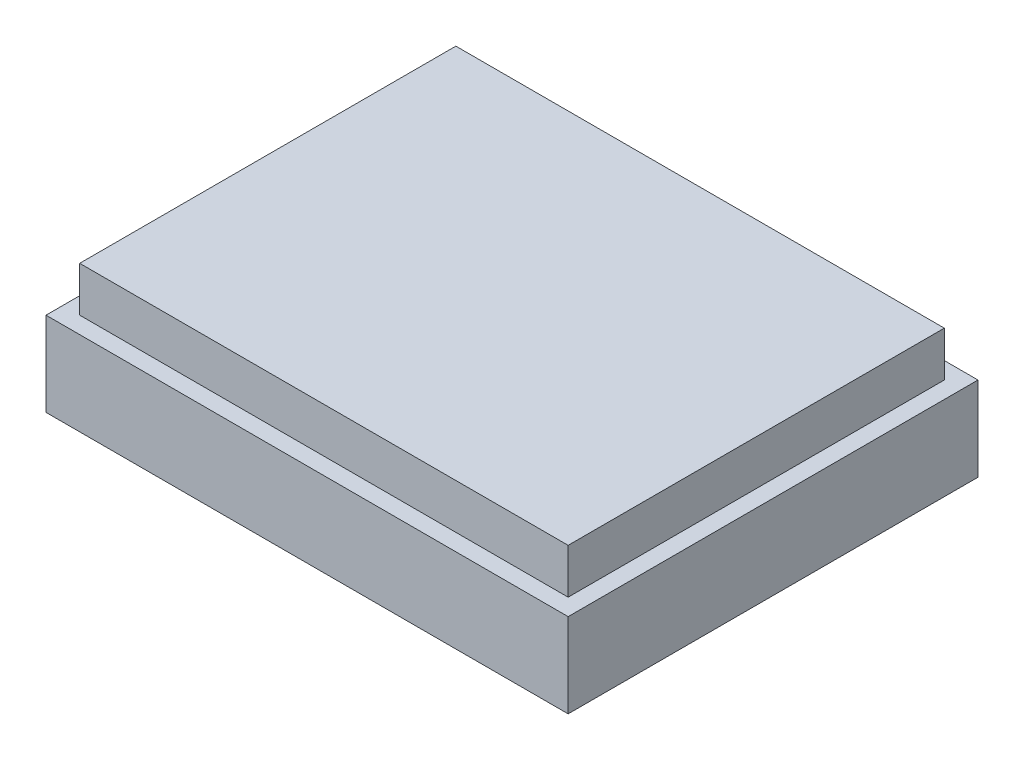
from build123d import *

# Parameters (mm, degrees)
SKETCH1_W           = 118.11
SKETCH1_H           = 92.71
BOSS_EXTRUDE1_DEPTH = 19.05
SKETCH3_W           = 110.49
SKETCH3_H           = 85.09
BOSS_EXTRUDE2_DEPTH = 10.16
CUT_EXTRUDE1_DEPTH  = 2.54


with BuildPart() as part:
    # Sketch1 → Boss-Extrude1 (new body)
    with BuildSketch(Plane(origin=(0, 0, 0), x_dir=(1, 0, 0), z_dir=(0, 1, 0))):
        Rectangle(SKETCH1_W, SKETCH1_H)
    extrude(amount=BOSS_EXTRUDE1_DEPTH)

    # Sketch3 → Boss-Extrude2 (add)
    with BuildSketch(Plane(origin=(0, 19.05, 0), x_dir=(1, 0, 0), z_dir=(0, 1, 0))):
        Rectangle(SKETCH3_W, SKETCH3_H)
    extrude(amount=BOSS_EXTRUDE2_DEPTH)

    # Sketch4 → Cut-Extrude1 (cut)
    with BuildSketch(Plane(origin=(0, 0, -46.355), x_dir=(-1, 0, 0), z_dir=(0, 0, -1))):
        Polygon((38.038942308, 5.250961538), (38.038942308, 4.7625), (35.535576923, 4.7625), (35.535576923, 5.250961538), (36.573557692, 5.250961538), (36.573557692, 9.525), (37.000961538, 9.525), (37.000961538, 5.250961538), align=None)
        with BuildLine():
            add(Edge.make_bspline(
                [(32.452163462, 4.640384615), (32.363968549, 4.642580619), (32.190746463, 4.646893751), (31.936399427, 4.680999474), (31.692851895, 4.737135465), (31.459958405, 4.816406092), (31.238624732, 4.919189844), (31.028151115, 5.043971626), (30.82926101, 5.191977796), (30.642468832, 5.359694946), (30.472692804, 5.544051134), (30.324960148, 5.74197049), (30.19922588, 5.949469449), (30.096496487, 6.167899319), (30.015775283, 6.396284876), (29.960105083, 6.635986661), (29.924536089, 6.885412912), (29.920378385, 7.055538998), (29.918269231, 7.141841947)],
                knots=[0, 0, 0, 0, 0.000264513, 0.000519526, 0.0007683, 0.001013279, 0.001256153, 0.001499123, 0.001746029, 0.00199869, 0.00225122, 0.002496596, 0.002738419, 0.002977836, 0.003219521, 0.003463651, 0.00371501, 0.003973804, 0.003973804, 0.003973804, 0.003973804], degree=3))
            add(Edge.make_bspline(
                [(29.918269231, 7.141841947), (29.920379091, 7.227508674), (29.924537871, 7.396367716), (29.960133984, 7.64421821), (30.016023544, 7.882447136), (30.095497891, 8.110500404), (30.198302954, 8.328489989), (30.324235066, 8.536134129), (30.471635811, 8.734630595), (30.64071575, 8.919884217), (30.825352425, 9.089675905), (31.022048982, 9.239774311), (31.230568068, 9.364814889), (31.44765521, 9.469079997), (31.675470907, 9.548046887), (31.912408435, 9.605591493), (32.159811246, 9.640802022), (32.32834225, 9.644987838), (32.414002404, 9.647115385)],
                knots=[0, 0, 0, 0, 0.000256888, 0.000506357, 0.000749559, 0.000990028, 0.001229445, 0.001471268, 0.001717408, 0.00197, 0.002222531, 0.002469054, 0.002710877, 0.002950702, 0.003190271, 0.003432768, 0.003681292, 0.00393818, 0.00393818, 0.00393818, 0.00393818], degree=3))
            add(Edge.make_bspline(
                [(32.414002404, 9.647115385), (32.500304949, 9.645007395), (32.67043024, 9.640851985), (32.920169287, 9.605222517), (33.160041804, 9.549527977), (33.389309229, 9.469858929), (33.608046797, 9.367283655), (33.816233354, 9.241233876), (34.014119067, 9.092701524), (34.199690222, 8.923754364), (34.369277171, 8.739471741), (34.518438685, 8.54303345), (34.64376176, 8.336307732), (34.746380335, 8.12014675), (34.827547721, 7.895109243), (34.882940478, 7.65977964), (34.918774793, 7.415476622), (34.922904543, 7.249139108), (34.925, 7.164738582)],
                knots=[0, 0, 0, 0, 0.000258795, 0.000510153, 0.000755211, 0.000996582, 0.001236862, 0.001478685, 0.001725396, 0.001977988, 0.002230519, 0.002475705, 0.002716712, 0.002954404, 0.003192493, 0.003432911, 0.0036786, 0.003931676, 0.003931676, 0.003931676, 0.003931676], degree=3))
            add(Edge.make_bspline(
                [(34.925, 7.164738582), (34.924273181, 7.108088155), (34.922828712, 6.995501973), (34.905413058, 6.828319444), (34.880192672, 6.663807521), (34.843858838, 6.502519214), (34.796991274, 6.344428184), (34.739234953, 6.189857736), (34.673046187, 6.037534665), (34.594239318, 5.890357947), (34.508258665, 5.74809658), (34.414505402, 5.612529422), (34.312325837, 5.48607807), (34.203179582, 5.366710653), (34.085555807, 5.256464501), (33.961224747, 5.152935995), (33.829535845, 5.057196823), (33.690280833, 4.971257772), (33.547010068, 4.892321709), (33.398684116, 4.826416592), (33.248432504, 4.768165307), (33.094931758, 4.72187281), (32.938536949, 4.685032964), (32.779052568, 4.66000122), (32.616642881, 4.642546869), (32.507225825, 4.641108468), (32.452163462, 4.640384615)],
                knots=[0, 0, 0, 0, 0.000169884, 0.000337624, 0.000503726, 0.000668982, 0.000833191, 0.000998003, 0.001163743, 0.001331035, 0.001498415, 0.001662233, 0.001825084, 0.00198578, 0.002147078, 0.002308317, 0.002470905, 0.002635033, 0.002798962, 0.002961217, 0.003121564, 0.003282119, 0.003441795, 0.003603186, 0.00376618, 0.003931295, 0.003931295, 0.003931295, 0.003931295], degree=3))
        make_face()
        with BuildLine():
            add(Edge.make_bspline(
                [(32.43117488, 5.128846154), (32.476371188, 5.129394909), (32.566331724, 5.130487172), (32.700058819, 5.144964437), (32.832075073, 5.165430239), (32.96209045, 5.19522984), (33.09022122, 5.233412549), (33.216609606, 5.280562729), (33.341368473, 5.33560737), (33.463356966, 5.399501828), (33.58062688, 5.471120882), (33.693882845, 5.546631145), (33.798799478, 5.630312434), (33.897403278, 5.719061547), (33.989455022, 5.814100432), (34.074967005, 5.91472898), (34.153854983, 6.021402758), (34.225173358, 6.133677308), (34.288640946, 6.250927241), (34.345466193, 6.370910848), (34.392572141, 6.495038293), (34.429887073, 6.622534954), (34.4615589, 6.752838991), (34.481425813, 6.886660344), (34.496041786, 7.023537684), (34.497074042, 7.116042091), (34.497596154, 7.162830529)],
                knots=[0, 0, 0, 0, 0.000135525, 0.000269755, 0.000403074, 0.000536149, 0.000669563, 0.000803891, 0.00094057, 0.001078403, 0.001216658, 0.001352666, 0.001486464, 0.001618858, 0.00175042, 0.001883081, 0.00201474, 0.00214813, 0.002281755, 0.002414488, 0.002546137, 0.002679551, 0.002812842, 0.002948044, 0.003085122, 0.003225416, 0.003225416, 0.003225416, 0.003225416], degree=3))
            add(Edge.make_bspline(
                [(34.497596154, 7.162830529), (34.495857462, 7.231629701), (34.492436917, 7.366978956), (34.462615566, 7.565350069), (34.416314972, 7.756178715), (34.349187856, 7.93832748), (34.263553975, 8.112608614), (34.159098024, 8.27834388), (34.034863408, 8.435484386), (33.893826798, 8.582860379), (33.739606981, 8.717322735), (33.575926722, 8.835515853), (33.404080997, 8.934990477), (33.225060281, 9.018149028), (33.037336126, 9.08079722), (32.842112147, 9.125465352), (32.639384028, 9.154416038), (32.501236565, 9.157227838), (32.43117488, 9.158653846)],
                knots=[0, 0, 0, 0, 0.00020629, 0.000405837, 0.000600433, 0.000794504, 0.000986929, 0.001182003, 0.001381066, 0.001586873, 0.001793112, 0.00199407, 0.002191572, 0.002387937, 0.002585243, 0.002784034, 0.002988171, 0.003198232, 0.003198232, 0.003198232, 0.003198232], degree=3))
            add(Edge.make_bspline(
                [(32.43117488, 9.158653846), (32.38408105, 9.158007344), (32.290679841, 9.156725138), (32.151759741, 9.143792475), (32.015329415, 9.123095066), (31.881641381, 9.093147323), (31.75051885, 9.056164075), (31.622363511, 9.010283032), (31.497195275, 8.955309201), (31.37448402, 8.893944384), (31.256887663, 8.824736379), (31.145741642, 8.748693744), (31.04031504, 8.667852578), (30.941891218, 8.579746182), (30.850223773, 8.485508996), (30.766240083, 8.384454703), (30.687388888, 8.278580043), (30.616570728, 8.166334031), (30.552232488, 8.050011858), (30.497076563, 7.929678963), (30.449943546, 7.806097494), (30.411956344, 7.679145492), (30.382172294, 7.549116864), (30.361653969, 7.415823261), (30.34730025, 7.279535188), (30.346218419, 7.187355131), (30.345673077, 7.140887921)],
                knots=[0, 0, 0, 0, 0.000141247, 0.000280136, 0.000418167, 0.000554966, 0.00069086, 0.000826654, 0.00096295, 0.00110076, 0.001238037, 0.00137193, 0.001504554, 0.00163631, 0.001767872, 0.001898574, 0.002030233, 0.002163622, 0.00229641, 0.002428742, 0.002560391, 0.00269289, 0.002825966, 0.002960226, 0.003097304, 0.003236645, 0.003236645, 0.003236645, 0.003236645], degree=3))
            add(Edge.make_bspline(
                [(30.345673077, 7.140887921), (30.346218877, 7.09473861), (30.347301572, 7.00319295), (30.361646868, 6.867855193), (30.382194865, 6.735521359), (30.411807693, 6.606710971), (30.449975937, 6.48139119), (30.497039417, 6.35967973), (30.552536537, 6.241123122), (30.61622923, 6.126014561), (30.68782406, 6.015558535), (30.766058309, 5.909965307), (30.85227667, 5.811209004), (30.944038338, 5.716885007), (31.043549443, 5.628879914), (31.150827432, 5.547534057), (31.263200911, 5.469181131), (31.383212326, 5.399841241), (31.506620539, 5.33547279), (31.633380954, 5.280602316), (31.761908438, 5.233203114), (31.892374656, 5.195394285), (32.024554236, 5.165401291), (32.158483905, 5.144971853), (32.294113934, 5.130485616), (32.385342918, 5.129394376), (32.43117488, 5.128846154)],
                knots=[0, 0, 0, 0, 0.000138386, 0.000274515, 0.000407833, 0.000539979, 0.000670653, 0.000800519, 0.00093112, 0.001063073, 0.001194856, 0.001325749, 0.001456961, 0.001587841, 0.001720309, 0.001855027, 0.001991572, 0.002130978, 0.002270504, 0.00240893, 0.002545048, 0.002681207, 0.002816144, 0.002951346, 0.003087475, 0.003224908, 0.003224908, 0.003224908, 0.003224908], degree=3))
        make_face(mode=Mode.SUBTRACT)
        Polygon((29.307692308, 4.7625), (28.818276743, 4.7625), (27.56659405, 6.808886719), (26.316819411, 4.7625), (25.827403846, 4.7625), (27.353846154, 7.261095252), (27.353846154, 9.525), (27.78125, 9.525), (27.78125, 7.261095252), align=None)
        Polygon((23.751442308, 5.250961538), (23.751442308, 4.7625), (21.248076923, 4.7625), (21.248076923, 5.250961538), (22.286057692, 5.250961538), (22.286057692, 9.525), (22.713461538, 9.525), (22.713461538, 5.250961538), align=None)
        Polygon((20.759615385, 4.7625), (20.27019982, 4.7625), (19.018517127, 6.808886719), (17.768742488, 4.7625), (17.279326923, 4.7625), (18.805769231, 7.261095252), (18.805769231, 9.525), (19.233173077, 9.525), (19.233173077, 7.261095252), align=None)
        with BuildLine():
            Line((16.485576923, 4.7625), (15.551585036, 4.7625))
            add(Edge.make_bspline(
                [(15.551585036, 4.7625), (15.487344482, 4.762570616), (15.364256726, 4.762705919), (15.187751597, 4.766808127), (15.027446212, 4.772287304), (14.88368623, 4.779882666), (14.756029325, 4.788858741), (14.645053142, 4.801448123), (14.549885389, 4.814593025), (14.492862684, 4.827957153), (14.466856971, 4.834051983)],
                knots=[0, 0, 0, 0, 0.000192716, 0.000369252, 0.00052963, 0.000673891, 0.000801134, 0.000913442, 0.001008969, 0.001089062, 0.001089062, 0.001089062, 0.001089062], degree=3))
            add(Edge.make_bspline(
                [(14.466856971, 4.834051983), (14.433936693, 4.843062837), (14.368871863, 4.860872214), (14.275114203, 4.896537669), (14.185925384, 4.938846218), (14.100932335, 4.986994094), (14.021591086, 5.043255066), (13.945424449, 5.104381942), (13.874029748, 5.172846839), (13.808485022, 5.248559615), (13.747755003, 5.32903995), (13.696919624, 5.41634005), (13.652029984, 5.507431438), (13.617047079, 5.604538139), (13.589549172, 5.706378357), (13.569522416, 5.813217151), (13.556650792, 5.924824043), (13.555429437, 6.001108129), (13.554807692, 6.039941406)],
                knots=[0, 0, 0, 0, 0.000102348, 0.000202284, 0.000300438, 0.000398299, 0.000494901, 0.000591898, 0.000691084, 0.000791152, 0.00089209, 0.000993041, 0.00109374, 0.001196358, 0.001302122, 0.001409897, 0.001522205, 0.001638659, 0.001638659, 0.001638659, 0.001638659], degree=3))
            add(Edge.make_bspline(
                [(13.554807692, 6.039941406), (13.555381131, 6.079099738), (13.556503102, 6.15571566), (13.569969119, 6.267801489), (13.588107701, 6.374914727), (13.615998333, 6.476817872), (13.652527624, 6.57290576), (13.69537931, 6.664646794), (13.747064043, 6.750480204), (13.806452186, 6.830717603), (13.872517034, 6.905434306), (13.944979068, 6.974088865), (14.023545748, 7.036279411), (14.107967385, 7.092145365), (14.199067001, 7.140391231), (14.295462931, 7.183603849), (14.397993047, 7.219895543), (14.468944111, 7.238986448), (14.505018029, 7.248692909)],
                knots=[0, 0, 0, 0, 0.000117407, 0.000229715, 0.000338256, 0.0004431, 0.000546051, 0.000646337, 0.000746469, 0.000846072, 0.000945424, 0.001045301, 0.001145128, 0.001245677, 0.001348544, 0.001454032, 0.001562359, 0.001674403, 0.001674403, 0.001674403, 0.001674403], degree=3))
            add(Edge.make_bspline(
                [(14.505018029, 7.248692909), (14.534855205, 7.255033165), (14.600245112, 7.268928205), (14.707928992, 7.284545841), (14.833368646, 7.297354009), (14.976137272, 7.309306694), (15.136567804, 7.315640123), (15.314292291, 7.323076601), (15.509912211, 7.326585469), (15.646351007, 7.326807273), (15.717585637, 7.326923077)],
                knots=[0, 0, 0, 0, 9.1492e-05, 0.00020051, 0.000326199, 0.000469761, 0.000630219, 0.000807793, 0.001003406, 0.00121711, 0.00121711, 0.00121711, 0.00121711], degree=3))
            Line((15.717585637, 7.326923077), (16.058173077, 7.326923077))
            Line((16.058173077, 7.326923077), (16.058173077, 9.525))
            Line((16.058173077, 9.525), (16.485576923, 9.525))
            Line((16.485576923, 9.525), (16.485576923, 4.7625))
        make_face()
        with BuildLine():
            Line((16.058173077, 5.250961538), (16.058173077, 6.838461538))
            Line((16.058173077, 6.838461538), (15.224353966, 6.848955829))
            add(Edge.make_bspline(
                [(15.224353966, 6.848955829), (15.183640811, 6.848982674), (15.105044903, 6.849034498), (14.991204145, 6.84351876), (14.885840458, 6.837518259), (14.788798277, 6.827814024), (14.700520527, 6.815977882), (14.620793478, 6.800152902), (14.548980869, 6.784012443), (14.466260696, 6.756005884), (14.373605426, 6.713754434), (14.273041646, 6.650646627), (14.187118143, 6.571146659), (14.11339165, 6.480794119), (14.055115893, 6.380174846), (14.012880926, 6.272816989), (13.987101579, 6.159128202), (13.983861333, 6.081416796), (13.982211538, 6.041849459)],
                knots=[0, 0, 0, 0, 0.000122119, 0.000235748, 0.000341856, 0.000438684, 0.000528271, 0.000608913, 0.000682497, 0.000748868, 0.000870539, 0.000987247, 0.001103403, 0.001220068, 0.001335918, 0.001450719, 0.001565063, 0.001683673, 0.001683673, 0.001683673, 0.001683673], degree=3))
            add(Edge.make_bspline(
                [(13.982211538, 6.041849459), (13.983934937, 6.003563995), (13.987360841, 5.92745723), (14.012667979, 5.815863109), (14.055563175, 5.709725743), (14.11343916, 5.609903972), (14.185398907, 5.519791576), (14.26961357, 5.442063371), (14.364772898, 5.379151489), (14.452601003, 5.337271649), (14.531200241, 5.312712379), (14.599142133, 5.294981829), (14.676245787, 5.282753446), (14.761781515, 5.271053183), (14.855639803, 5.261608525), (14.958417473, 5.255049852), (15.06977218, 5.251251668), (15.147074773, 5.25106059), (15.187146935, 5.250961538)],
                knots=[0, 0, 0, 0, 0.000114805, 0.000228218, 0.000341245, 0.000457095, 0.000573161, 0.000685918, 0.000799431, 0.00091424, 0.000976391, 0.00104627, 0.001124692, 0.001210368, 0.001305297, 0.001407596, 0.001519283, 0.001639494, 0.001639494, 0.001639494, 0.001639494], degree=3))
            Line((15.187146935, 5.250961538), (16.058173077, 5.250961538))
        make_face(mode=Mode.SUBTRACT)
        Polygon((12.577884615, 4.7625), (9.891346154, 4.7625), (9.891346154, 5.250961538), (12.150480769, 5.250961538), (12.150480769, 6.716346154), (9.891346154, 6.716346154), (9.891346154, 7.204807692), (12.150480769, 7.204807692), (12.150480769, 9.036538462), (9.891346154, 9.036538462), (9.891346154, 9.525), (12.577884615, 9.525), align=None)
        with BuildLine():
            Line((2.808653846, 5.636388221), (3.182632212, 5.922596154))
            add(Edge.make_bspline(
                [(3.182632212, 5.922596154), (3.209310497, 5.890802166), (3.262307388, 5.827642841), (3.347564641, 5.738945923), (3.436436555, 5.655876667), (3.528799476, 5.577901341), (3.626790896, 5.508153935), (3.726677066, 5.441202463), (3.832087294, 5.382584145), (3.977109315, 5.310974536), (4.167562585, 5.237879221), (4.406483388, 5.17501094), (4.656236805, 5.135367647), (4.826588455, 5.131044885), (4.913236178, 5.128846154)],
                knots=[0, 0, 0, 0, 0.000124485, 0.000247292, 0.000368787, 0.000489349, 0.000609572, 0.000729438, 0.000849902, 0.000971075, 0.001214507, 0.001460263, 0.001711228, 0.001971019, 0.001971019, 0.001971019, 0.001971019], degree=3))
            add(Edge.make_bspline(
                [(4.913236178, 5.128846154), (4.960973944, 5.129398312), (5.056006425, 5.130497503), (5.197050948, 5.144896887), (5.335728869, 5.165368475), (5.471524496, 5.195005349), (5.604168201, 5.233589868), (5.734669948, 5.278839216), (5.86149281, 5.335147415), (5.986162932, 5.397332384), (6.105600152, 5.467589672), (6.21863082, 5.544199074), (6.324745154, 5.626403782), (6.424213022, 5.714009537), (6.516032133, 5.808039072), (6.601177922, 5.90743591), (6.679541709, 6.012648936), (6.751042642, 6.123175433), (6.814995718, 6.238469437), (6.870453425, 6.358035708), (6.917331466, 6.481417471), (6.955361892, 6.608350304), (6.985126057, 6.738384896), (7.005729198, 6.871986841), (7.019995921, 7.008922611), (7.021085427, 7.101735713), (7.021634615, 7.148520132)],
                knots=[0, 0, 0, 0, 0.000143155, 0.000284981, 0.000424898, 0.00056356, 0.000701552, 0.000839143, 0.000977569, 0.001117512, 0.001256918, 0.001392926, 0.001526888, 0.001659357, 0.001790236, 0.001920826, 0.002051719, 0.002183502, 0.002315455, 0.00244692, 0.002578569, 0.002711069, 0.002844144, 0.002978405, 0.003116432, 0.003256726, 0.003256726, 0.003256726, 0.003256726], degree=3))
            add(Edge.make_bspline(
                [(7.021634615, 7.148520132), (7.019913614, 7.218910109), (7.016534657, 7.357111492), (6.986590325, 7.559568062), (6.940721476, 7.75370778), (6.873102084, 7.938216143), (6.78805997, 8.114631251), (6.681950862, 8.280813711), (6.558592798, 8.439198144), (6.416720285, 8.585948572), (6.26104254, 8.71999571), (6.094018794, 8.838038968), (5.916058456, 8.936438728), (5.729128191, 9.018321034), (5.531789065, 9.081263215), (5.324396072, 9.125573685), (5.107400248, 9.154478223), (4.959124029, 9.157245492), (4.883661358, 9.158653846)],
                knots=[0, 0, 0, 0, 0.000211056, 0.00041438, 0.000612682, 0.000808546, 0.001002685, 0.001199075, 0.001398888, 0.001604006, 0.001810343, 0.002014411, 0.002216417, 0.002419358, 0.002625728, 0.002836619, 0.003054944, 0.003281211, 0.003281211, 0.003281211, 0.003281211], degree=3))
            add(Edge.make_bspline(
                [(4.883661358, 9.158653846), (4.800518056, 9.156355899), (4.636872149, 9.151832991), (4.396885656, 9.113516298), (4.167148418, 9.051388917), (3.947648077, 8.964442101), (3.739003433, 8.851413977), (3.540887977, 8.714392937), (3.353134483, 8.552075598), (3.240234274, 8.428137485), (3.182632212, 8.364903846)],
                knots=[0, 0, 0, 0, 0.00024931, 0.000490701, 0.000726995, 0.000962085, 0.001197283, 0.001437307, 0.001683487, 0.001939923, 0.001939923, 0.001939923, 0.001939923], degree=3))
            Line((3.182632212, 8.364903846), (2.808653846, 8.6482497))
            add(Edge.make_bspline(
                [(2.808653846, 8.6482497), (2.83875129, 8.687081101), (2.898802011, 8.764557904), (2.996020896, 8.873803715), (3.098508048, 8.97647235), (3.206540136, 9.072029118), (3.320258189, 9.160951645), (3.439612505, 9.242826459), (3.564007786, 9.318561797), (3.693599794, 9.387206984), (3.828395624, 9.448289734), (3.967240103, 9.501675918), (4.11038757, 9.546503914), (4.25670919, 9.584168711), (4.407708415, 9.61106857), (4.561657551, 9.632476742), (4.71998996, 9.645180484), (4.826715306, 9.646464632), (4.880799279, 9.647115385)],
                knots=[0, 0, 0, 0, 0.000147356, 0.000294007, 0.000438371, 0.000582327, 0.000726414, 0.000871165, 0.001016293, 0.001163102, 0.001310828, 0.001460011, 0.001609065, 0.001760623, 0.001912939, 0.00206891, 0.002226812, 0.002389041, 0.002389041, 0.002389041, 0.002389041], degree=3))
            add(Edge.make_bspline(
                [(4.880799279, 9.647115385), (4.932021554, 9.646758888), (5.033307261, 9.646053959), (5.182848063, 9.634634617), (5.328430314, 9.619054796), (5.469637929, 9.595595904), (5.607241488, 9.567913069), (5.739993569, 9.530804681), (5.869200481, 9.489235994), (5.994343116, 9.440379565), (6.115527921, 9.385248617), (6.232364036, 9.322939388), (6.344797725, 9.253975851), (6.453934387, 9.179878141), (6.558161813, 9.098266169), (6.658383217, 9.010273356), (6.755160586, 8.916196277), (6.815035669, 8.848358066), (6.845139724, 8.8142503)],
                knots=[0, 0, 0, 0, 0.000153625, 0.000303774, 0.00044969, 0.000592731, 0.00073306, 0.000870536, 0.001005998, 0.001140112, 0.001273311, 0.001405191, 0.001537068, 0.001668848, 0.001800718, 0.001933903, 0.002068829, 0.002205265, 0.002205265, 0.002205265, 0.002205265], degree=3))
            add(Edge.make_bspline(
                [(6.845139724, 8.8142503), (6.893354365, 8.75500196), (6.989201558, 8.637220578), (7.111883168, 8.446349435), (7.216547832, 8.247241246), (7.302117735, 8.03874274), (7.367845402, 7.820772866), (7.414056226, 7.593682273), (7.443875999, 7.357924926), (7.447298688, 7.197584984), (7.449038462, 7.116083233)],
                knots=[0, 0, 0, 0, 0.000229016, 0.000455267, 0.000679301, 0.00090306, 0.001130321, 0.001361207, 0.001597636, 0.001842053, 0.001842053, 0.001842053, 0.001842053], degree=3))
            add(Edge.make_bspline(
                [(7.449038462, 7.116083233), (7.446912822, 7.030422432), (7.44273076, 6.861890154), (7.407493002, 6.614496585), (7.350119124, 6.377817116), (7.271114911, 6.150941061), (7.166887232, 5.935166518), (7.040711197, 5.72958218), (6.891354371, 5.534355912), (6.720692534, 5.351983701), (6.533492834, 5.185247096), (6.333036598, 5.038552493), (6.119700483, 4.916472893), (5.895838874, 4.814424462), (5.659774379, 4.73598684), (5.412010951, 4.681077676), (5.153014067, 4.646900459), (4.97630841, 4.642579908), (4.886523438, 4.640384615)],
                knots=[0, 0, 0, 0, 0.000256888, 0.000505412, 0.000747909, 0.000986578, 0.001224681, 0.00146537, 0.001709038, 0.001960816, 0.002213552, 0.002460099, 0.002704576, 0.002949655, 0.00319704, 0.003449322, 0.00371001, 0.003979289, 0.003979289, 0.003979289, 0.003979289], degree=3))
            add(Edge.make_bspline(
                [(4.886523438, 4.640384615), (4.831803103, 4.641040748), (4.723489713, 4.642339497), (4.563260948, 4.65500133), (4.407269352, 4.676115209), (4.255080978, 4.704889919), (4.106444801, 4.740680127), (3.962028803, 4.785494196), (3.822246775, 4.839677367), (3.686156166, 4.899981895), (3.555501884, 4.969046861), (3.430348921, 5.044117372), (3.311713494, 5.126639034), (3.198824416, 5.215408296), (3.092203608, 5.311108048), (2.990250911, 5.4121297), (2.895993524, 5.521153051), (2.837820366, 5.597906183), (2.808653846, 5.636388221)],
                knots=[0, 0, 0, 0, 0.000164137, 0.000324892, 0.000481809, 0.000636175, 0.000789355, 0.00094023, 0.001089413, 0.001238879, 0.001386531, 0.001532475, 0.001676442, 0.001819777, 0.001963021, 0.002106036, 0.002250082, 0.002394921, 0.002394921, 0.002394921, 0.002394921], degree=3))
        make_face()
        with BuildLine():
            add(Edge.make_bspline(
                [(-0.396875, 4.640384615), (-0.485069913, 4.642580619), (-0.658291998, 4.646893751), (-0.912639034, 4.680999474), (-1.156186566, 4.737135465), (-1.389080057, 4.816406092), (-1.61041373, 4.919189844), (-1.820887346, 5.043971626), (-2.019777451, 5.191977796), (-2.20656963, 5.359694946), (-2.376345657, 5.544051134), (-2.524078314, 5.74197049), (-2.649812582, 5.949469449), (-2.752541974, 6.167899319), (-2.833263179, 6.396284876), (-2.888933379, 6.635986661), (-2.924502372, 6.885412912), (-2.928660077, 7.055538998), (-2.930769231, 7.141841947)],
                knots=[0, 0, 0, 0, 0.000264513, 0.000519526, 0.0007683, 0.001013279, 0.001256153, 0.001499123, 0.001746029, 0.00199869, 0.00225122, 0.002496596, 0.002738419, 0.002977836, 0.003219521, 0.003463651, 0.00371501, 0.003973804, 0.003973804, 0.003973804, 0.003973804], degree=3))
            add(Edge.make_bspline(
                [(-2.930769231, 7.141841947), (-2.92865937, 7.227508674), (-2.924500591, 7.396367716), (-2.888904478, 7.64421821), (-2.833014918, 7.882447136), (-2.753540571, 8.110500404), (-2.650735508, 8.328489989), (-2.524803396, 8.536134129), (-2.377402651, 8.734630595), (-2.208322711, 8.919884217), (-2.023686036, 9.089675905), (-1.826989479, 9.239774311), (-1.618470393, 9.364814889), (-1.401383251, 9.469079997), (-1.173567554, 9.548046887), (-0.936630027, 9.605591493), (-0.689227215, 9.640802022), (-0.520696211, 9.644987838), (-0.435036058, 9.647115385)],
                knots=[0, 0, 0, 0, 0.000256888, 0.000506357, 0.000749559, 0.000990028, 0.001229445, 0.001471268, 0.001717408, 0.00197, 0.002222531, 0.002469054, 0.002710877, 0.002950702, 0.003190271, 0.003432768, 0.003681292, 0.00393818, 0.00393818, 0.00393818, 0.00393818], degree=3))
            add(Edge.make_bspline(
                [(-0.435036058, 9.647115385), (-0.348733512, 9.645007395), (-0.178608221, 9.640851985), (0.071130825, 9.605222517), (0.311003343, 9.549527977), (0.540270768, 9.469858929), (0.759008336, 9.367283655), (0.967194892, 9.241233876), (1.165080606, 9.092701524), (1.35065176, 8.923754364), (1.520238709, 8.739471741), (1.669400223, 8.54303345), (1.794723298, 8.336307732), (1.897341874, 8.12014675), (1.97850926, 7.895109243), (2.033902017, 7.65977964), (2.069736332, 7.415476622), (2.073866082, 7.249139108), (2.075961538, 7.164738582)],
                knots=[0, 0, 0, 0, 0.000258795, 0.000510153, 0.000755211, 0.000996582, 0.001236862, 0.001478685, 0.001725396, 0.001977988, 0.002230519, 0.002475705, 0.002716712, 0.002954404, 0.003192493, 0.003432911, 0.0036786, 0.003931676, 0.003931676, 0.003931676, 0.003931676], degree=3))
            add(Edge.make_bspline(
                [(2.075961538, 7.164738582), (2.075234719, 7.108088155), (2.07379025, 6.995501973), (2.056374597, 6.828319444), (2.03115421, 6.663807521), (1.994820376, 6.502519214), (1.947952813, 6.344428184), (1.890196492, 6.189857736), (1.824007725, 6.037534665), (1.745200856, 5.890357947), (1.659220203, 5.74809658), (1.56546694, 5.612529422), (1.463287375, 5.48607807), (1.35414112, 5.366710653), (1.236517345, 5.256464501), (1.112186285, 5.152935995), (0.980497384, 5.057196823), (0.841242371, 4.971257772), (0.697971607, 4.892321709), (0.549645655, 4.826416592), (0.399394043, 4.768165307), (0.245893296, 4.72187281), (0.089498488, 4.685032964), (-0.069985894, 4.66000122), (-0.232395581, 4.642546869), (-0.341812637, 4.641108468), (-0.396875, 4.640384615)],
                knots=[0, 0, 0, 0, 0.000169884, 0.000337624, 0.000503726, 0.000668982, 0.000833191, 0.000998003, 0.001163743, 0.001331035, 0.001498415, 0.001662233, 0.001825084, 0.00198578, 0.002147078, 0.002308317, 0.002470905, 0.002635033, 0.002798962, 0.002961217, 0.003121564, 0.003282119, 0.003441795, 0.003603186, 0.00376618, 0.003931295, 0.003931295, 0.003931295, 0.003931295], degree=3))
        make_face()
        with BuildLine():
            add(Edge.make_bspline(
                [(-0.417863582, 5.128846154), (-0.372667274, 5.129394909), (-0.282706738, 5.130487172), (-0.148979643, 5.144964437), (-0.016963388, 5.165430239), (0.113051988, 5.19522984), (0.241182758, 5.233412549), (0.367571144, 5.280562729), (0.492330012, 5.33560737), (0.614318505, 5.399501828), (0.731588419, 5.471120882), (0.844844384, 5.546631145), (0.949761017, 5.630312434), (1.048364817, 5.719061547), (1.14041656, 5.814100432), (1.225928544, 5.91472898), (1.304816521, 6.021402758), (1.376134896, 6.133677308), (1.439602485, 6.250927241), (1.496427731, 6.370910848), (1.543533679, 6.495038293), (1.580848611, 6.622534954), (1.612520438, 6.752838991), (1.632387352, 6.886660344), (1.647003325, 7.023537684), (1.648035581, 7.116042091), (1.648557692, 7.162830529)],
                knots=[0, 0, 0, 0, 0.000135525, 0.000269755, 0.000403074, 0.000536149, 0.000669563, 0.000803891, 0.00094057, 0.001078403, 0.001216658, 0.001352666, 0.001486464, 0.001618858, 0.00175042, 0.001883081, 0.00201474, 0.00214813, 0.002281755, 0.002414488, 0.002546137, 0.002679551, 0.002812842, 0.002948044, 0.003085122, 0.003225416, 0.003225416, 0.003225416, 0.003225416], degree=3))
            add(Edge.make_bspline(
                [(1.648557692, 7.162830529), (1.646819, 7.231629701), (1.643398456, 7.366978956), (1.613577104, 7.565350069), (1.56727651, 7.756178715), (1.500149395, 7.93832748), (1.414515513, 8.112608614), (1.310059563, 8.27834388), (1.185824947, 8.435484386), (1.044788336, 8.582860379), (0.890568519, 8.717322735), (0.72688826, 8.835515853), (0.555042535, 8.934990477), (0.376021819, 9.018149028), (0.188297664, 9.08079722), (-0.006926315, 9.125465352), (-0.209654433, 9.154416038), (-0.347801896, 9.157227838), (-0.417863582, 9.158653846)],
                knots=[0, 0, 0, 0, 0.00020629, 0.000405837, 0.000600433, 0.000794504, 0.000986929, 0.001182003, 0.001381066, 0.001586873, 0.001793112, 0.00199407, 0.002191572, 0.002387937, 0.002585243, 0.002784034, 0.002988171, 0.003198232, 0.003198232, 0.003198232, 0.003198232], degree=3))
            add(Edge.make_bspline(
                [(-0.417863582, 9.158653846), (-0.464957412, 9.158007344), (-0.558358621, 9.156725138), (-0.697278721, 9.143792475), (-0.833709046, 9.123095066), (-0.967397081, 9.093147323), (-1.098519611, 9.056164075), (-1.22667495, 9.010283032), (-1.351843186, 8.955309201), (-1.474554442, 8.893944384), (-1.592150799, 8.824736379), (-1.70329682, 8.748693744), (-1.808723421, 8.667852578), (-1.907147244, 8.579746182), (-1.998814688, 8.485508996), (-2.082798378, 8.384454703), (-2.161649574, 8.278580043), (-2.232467733, 8.166334031), (-2.296805974, 8.050011858), (-2.351961898, 7.929678963), (-2.399094915, 7.806097494), (-2.437082118, 7.679145492), (-2.466866168, 7.549116864), (-2.487384493, 7.415823261), (-2.501738211, 7.279535188), (-2.502820042, 7.187355131), (-2.503365385, 7.140887921)],
                knots=[0, 0, 0, 0, 0.000141247, 0.000280136, 0.000418167, 0.000554966, 0.00069086, 0.000826654, 0.00096295, 0.00110076, 0.001238037, 0.00137193, 0.001504554, 0.00163631, 0.001767872, 0.001898574, 0.002030233, 0.002163622, 0.00229641, 0.002428742, 0.002560391, 0.00269289, 0.002825966, 0.002960226, 0.003097304, 0.003236645, 0.003236645, 0.003236645, 0.003236645], degree=3))
            add(Edge.make_bspline(
                [(-2.503365385, 7.140887921), (-2.502819584, 7.09473861), (-2.501736889, 7.00319295), (-2.487391593, 6.867855193), (-2.466843596, 6.735521359), (-2.437230768, 6.606710971), (-2.399062525, 6.48139119), (-2.351999045, 6.35967973), (-2.296501925, 6.241123122), (-2.232809232, 6.126014561), (-2.161214402, 6.015558535), (-2.082980153, 5.909965307), (-1.996761792, 5.811209004), (-1.905000123, 5.716885007), (-1.805489019, 5.628879914), (-1.698211029, 5.547534057), (-1.58583755, 5.469181131), (-1.465826135, 5.399841241), (-1.342417922, 5.33547279), (-1.215657507, 5.280602316), (-1.087130024, 5.233203114), (-0.956663806, 5.195394285), (-0.824484226, 5.165401291), (-0.690554556, 5.144971853), (-0.554924527, 5.130485616), (-0.463695544, 5.129394376), (-0.417863582, 5.128846154)],
                knots=[0, 0, 0, 0, 0.000138386, 0.000274515, 0.000407833, 0.000539979, 0.000670653, 0.000800519, 0.00093112, 0.001063073, 0.001194856, 0.001325749, 0.001456961, 0.001587841, 0.001720309, 0.001855027, 0.001991572, 0.002130978, 0.002270504, 0.00240893, 0.002545048, 0.002681207, 0.002816144, 0.002951346, 0.003087475, 0.003224908, 0.003224908, 0.003224908, 0.003224908], degree=3))
        make_face(mode=Mode.SUBTRACT)
        Polygon((-3.907692308, 9.525), (-3.907692308, 4.7625), (-3.997370793, 4.7625), (-7.14375, 8.510869892), (-7.14375, 4.7625), (-7.571153846, 4.7625), (-7.571153846, 9.525), (-7.473843149, 9.525), (-4.335096154, 5.785216346), (-4.335096154, 9.525), align=None)
        Polygon((-8.425961538, 4.7625), (-8.883894231, 4.7625), (-10.471394231, 8.515640024), (-12.058894231, 4.7625), (-12.516826923, 4.7625), (-10.501923077, 9.525), (-10.440865385, 9.525), align=None)
        Polygon((-13.432692308, 4.7625), (-16.119230769, 4.7625), (-16.119230769, 5.250961538), (-13.860096154, 5.250961538), (-13.860096154, 6.716346154), (-16.119230769, 6.716346154), (-16.119230769, 7.204807692), (-13.860096154, 7.204807692), (-13.860096154, 9.036538462), (-16.119230769, 9.036538462), (-16.119230769, 9.525), (-13.432692308, 9.525), align=None)
        with BuildLine():
            Line((-16.974038462, 4.7625), (-17.927110877, 4.7625))
            add(Edge.make_bspline(
                [(-17.927110877, 4.7625), (-17.990712199, 4.762711708), (-18.112833781, 4.763118211), (-18.287785267, 4.765384838), (-18.446753567, 4.771881372), (-18.589655562, 4.777471981), (-18.716488632, 4.787666372), (-18.827641695, 4.797409967), (-18.922602812, 4.810164841), (-18.980087346, 4.822010435), (-19.006114784, 4.827373798)],
                knots=[0, 0, 0, 0, 0.000190808, 0.000366372, 0.000524844, 0.000668103, 0.000795347, 0.000906511, 0.001002844, 0.001082549, 0.001082549, 0.001082549, 0.001082549], degree=3))
            add(Edge.make_bspline(
                [(-19.006114784, 4.827373798), (-19.04095867, 4.835981765), (-19.109903127, 4.853014067), (-19.209158813, 4.889031854), (-19.303779347, 4.930645392), (-19.393418228, 4.979895354), (-19.478051965, 5.035950093), (-19.557672033, 5.09903495), (-19.631210882, 5.169690434), (-19.701284912, 5.244989716), (-19.762472925, 5.328211235), (-19.817558369, 5.415131719), (-19.863800712, 5.507424605), (-19.900188275, 5.604624387), (-19.930693035, 5.705777586), (-19.951195081, 5.811883731), (-19.963964114, 5.922597608), (-19.965225695, 5.997928502), (-19.965865385, 6.0361253)],
                knots=[0, 0, 0, 0, 0.000107606, 0.000212917, 0.000316274, 0.000417464, 0.000519335, 0.000620502, 0.000721728, 0.00082505, 0.000928657, 0.001031098, 0.001133495, 0.001237676, 0.001342124, 0.001450081, 0.00156144, 0.001675987, 0.001675987, 0.001675987, 0.001675987], degree=3))
            add(Edge.make_bspline(
                [(-19.965865385, 6.0361253), (-19.96386655, 6.099582427), (-19.959966305, 6.223403715), (-19.92360035, 6.403099823), (-19.864035664, 6.570729013), (-19.781943141, 6.726058004), (-19.677449912, 6.866140846), (-19.551872813, 6.988764025), (-19.405853156, 7.092324886), (-19.26928023, 7.163376765), (-19.148581629, 7.209094589), (-19.048923364, 7.241423299), (-18.940130496, 7.265980078), (-18.823763823, 7.288298759), (-18.698924519, 7.305329706), (-18.565863979, 7.317424915), (-18.42424941, 7.325202226), (-18.327176377, 7.326338525), (-18.277238582, 7.326923077)],
                knots=[0, 0, 0, 0, 0.000190196, 0.000371122, 0.000547346, 0.000722326, 0.00089615, 0.001069534, 0.001246646, 0.001431405, 0.001529558, 0.001633652, 0.00174542, 0.001863862, 0.001989068, 0.002123207, 0.002264609, 0.002414418, 0.002414418, 0.002414418, 0.002414418], degree=3))
            Line((-18.277238582, 7.326923077), (-20.026923077, 9.525))
            Line((-20.026923077, 9.525), (-19.498392428, 9.525))
            Line((-19.498392428, 9.525), (-17.748707933, 7.326923077))
            Line((-17.748707933, 7.326923077), (-17.401442308, 7.326923077))
            Line((-17.401442308, 7.326923077), (-17.401442308, 9.525))
            Line((-17.401442308, 9.525), (-16.974038462, 9.525))
            Line((-16.974038462, 9.525), (-16.974038462, 4.7625))
        make_face()
        with BuildLine():
            Line((-17.401442308, 5.250961538), (-17.401442308, 6.838461538))
            Line((-17.401442308, 6.838461538), (-18.273422476, 6.845139724))
            add(Edge.make_bspline(
                [(-18.273422476, 6.845139724), (-18.314135105, 6.845157745), (-18.393047777, 6.845192676), (-18.507212541, 6.839758148), (-18.613511929, 6.833576466), (-18.711538021, 6.824118803), (-18.801339014, 6.811937371), (-18.882855595, 6.796676275), (-18.956267904, 6.778971659), (-19.041615498, 6.751289126), (-19.138015747, 6.709322249), (-19.240620844, 6.644248957), (-19.330346062, 6.565552402), (-19.404942675, 6.474426014), (-19.464858759, 6.37380365), (-19.506475816, 6.265962541), (-19.533901215, 6.152601831), (-19.536923905, 6.074766094), (-19.538461538, 6.035171274)],
                knots=[0, 0, 0, 0, 0.000122119, 0.000236702, 0.000342809, 0.000441536, 0.000532068, 0.000614584, 0.000690247, 0.000758432, 0.000883584, 0.001004535, 0.001121476, 0.001240087, 0.001356419, 0.00147122, 0.001585775, 0.001704385, 0.001704385, 0.001704385, 0.001704385], degree=3))
            add(Edge.make_bspline(
                [(-19.538461538, 6.035171274), (-19.536846049, 5.996864339), (-19.533644737, 5.920953972), (-19.506912488, 5.810073265), (-19.463262959, 5.704640266), (-19.403517957, 5.606105801), (-19.329158894, 5.517324857), (-19.242547334, 5.441594585), (-19.145721438, 5.378680033), (-19.055957531, 5.337168859), (-18.975138403, 5.312743619), (-18.905290842, 5.295013364), (-18.825680975, 5.282595897), (-18.7372458, 5.271175145), (-18.639596829, 5.261503518), (-18.532674554, 5.255083968), (-18.416555425, 5.251246993), (-18.336073373, 5.251058904), (-18.294411058, 5.250961538)],
                knots=[0, 0, 0, 0, 0.000114805, 0.000227501, 0.000340003, 0.000456007, 0.000571806, 0.000686055, 0.00079984, 0.000917247, 0.000981217, 0.001052947, 0.001133249, 0.001222709, 0.001320487, 0.001427546, 0.001544, 0.001668981, 0.001668981, 0.001668981, 0.001668981], degree=3))
            Line((-18.294411058, 5.250961538), (-17.401442308, 5.250961538))
        make_face(mode=Mode.SUBTRACT)
        Polygon((-20.454326923, 5.250961538), (-20.454326923, 4.7625), (-22.957692308, 4.7625), (-22.957692308, 5.250961538), (-21.919711538, 5.250961538), (-21.919711538, 9.525), (-21.492307692, 9.525), (-21.492307692, 5.250961538), align=None)
        Polygon((-23.8125, 4.7625), (-26.499038462, 4.7625), (-26.499038462, 5.250961538), (-24.239903846, 5.250961538), (-24.239903846, 6.716346154), (-26.499038462, 6.716346154), (-26.499038462, 7.204807692), (-24.239903846, 7.204807692), (-24.239903846, 9.036538462), (-26.499038462, 9.036538462), (-26.499038462, 9.525), (-23.8125, 9.525), align=None)
        with BuildLine():
            Line((-27.353846154, 4.7625), (-28.30691857, 4.7625))
            add(Edge.make_bspline(
                [(-28.30691857, 4.7625), (-28.370519891, 4.762711708), (-28.492641473, 4.763118211), (-28.667592959, 4.765384838), (-28.826561259, 4.771881372), (-28.969463254, 4.777471981), (-29.096296324, 4.787666372), (-29.207449388, 4.797409967), (-29.302410505, 4.810164841), (-29.359895038, 4.822010435), (-29.385922476, 4.827373798)],
                knots=[0, 0, 0, 0, 0.000190808, 0.000366372, 0.000524844, 0.000668103, 0.000795347, 0.000906511, 0.001002844, 0.001082549, 0.001082549, 0.001082549, 0.001082549], degree=3))
            add(Edge.make_bspline(
                [(-29.385922476, 4.827373798), (-29.420766362, 4.835981765), (-29.489710819, 4.853014067), (-29.588966505, 4.889031854), (-29.683587039, 4.930645392), (-29.77322592, 4.979895354), (-29.857859657, 5.035950093), (-29.937479725, 5.09903495), (-30.011018574, 5.169690434), (-30.081092604, 5.244989716), (-30.142280617, 5.328211235), (-30.197366061, 5.415131719), (-30.243608404, 5.507424605), (-30.279995967, 5.604624387), (-30.310500727, 5.705777586), (-30.331002773, 5.811883731), (-30.343771807, 5.922597608), (-30.345033388, 5.997928502), (-30.345673077, 6.0361253)],
                knots=[0, 0, 0, 0, 0.000107606, 0.000212917, 0.000316274, 0.000417464, 0.000519335, 0.000620502, 0.000721728, 0.00082505, 0.000928657, 0.001031098, 0.001133495, 0.001237676, 0.001342124, 0.001450081, 0.00156144, 0.001675987, 0.001675987, 0.001675987, 0.001675987], degree=3))
            add(Edge.make_bspline(
                [(-30.345673077, 6.0361253), (-30.343674242, 6.099582427), (-30.339773998, 6.223403715), (-30.303408043, 6.403099823), (-30.243843357, 6.570729013), (-30.161750833, 6.726058004), (-30.057257605, 6.866140846), (-29.931680505, 6.988764025), (-29.785660848, 7.092324886), (-29.649087922, 7.163376765), (-29.528389321, 7.209094589), (-29.428731056, 7.241423299), (-29.319938188, 7.265980078), (-29.203571516, 7.288298759), (-29.078732211, 7.305329706), (-28.945671671, 7.317424915), (-28.804057102, 7.325202226), (-28.706984069, 7.326338525), (-28.657046274, 7.326923077)],
                knots=[0, 0, 0, 0, 0.000190196, 0.000371122, 0.000547346, 0.000722326, 0.00089615, 0.001069534, 0.001246646, 0.001431405, 0.001529558, 0.001633652, 0.00174542, 0.001863862, 0.001989068, 0.002123207, 0.002264609, 0.002414418, 0.002414418, 0.002414418, 0.002414418], degree=3))
            Line((-28.657046274, 7.326923077), (-30.406730769, 9.525))
            Line((-30.406730769, 9.525), (-29.87820012, 9.525))
            Line((-29.87820012, 9.525), (-28.128515625, 7.326923077))
            Line((-28.128515625, 7.326923077), (-27.78125, 7.326923077))
            Line((-27.78125, 7.326923077), (-27.78125, 9.525))
            Line((-27.78125, 9.525), (-27.353846154, 9.525))
            Line((-27.353846154, 9.525), (-27.353846154, 4.7625))
        make_face()
        with BuildLine():
            Line((-27.78125, 5.250961538), (-27.78125, 6.838461538))
            Line((-27.78125, 6.838461538), (-28.653230168, 6.845139724))
            add(Edge.make_bspline(
                [(-28.653230168, 6.845139724), (-28.693942798, 6.845157745), (-28.772855469, 6.845192676), (-28.887020233, 6.839758148), (-28.993319622, 6.833576466), (-29.091345713, 6.824118803), (-29.181146707, 6.811937371), (-29.262663287, 6.796676275), (-29.336075596, 6.778971659), (-29.421423191, 6.751289126), (-29.517823439, 6.709322249), (-29.620428536, 6.644248957), (-29.710153754, 6.565552402), (-29.784750367, 6.474426014), (-29.844666451, 6.37380365), (-29.886283509, 6.265962541), (-29.913708907, 6.152601831), (-29.916731597, 6.074766094), (-29.918269231, 6.035171274)],
                knots=[0, 0, 0, 0, 0.000122119, 0.000236702, 0.000342809, 0.000441536, 0.000532068, 0.000614584, 0.000690247, 0.000758432, 0.000883584, 0.001004535, 0.001121476, 0.001240087, 0.001356419, 0.00147122, 0.001585775, 0.001704385, 0.001704385, 0.001704385, 0.001704385], degree=3))
            add(Edge.make_bspline(
                [(-29.918269231, 6.035171274), (-29.916653741, 5.996864339), (-29.913452429, 5.920953972), (-29.88672018, 5.810073265), (-29.843070651, 5.704640266), (-29.783325649, 5.606105801), (-29.708966587, 5.517324857), (-29.622355026, 5.441594585), (-29.52552913, 5.378680033), (-29.435765224, 5.337168859), (-29.354946096, 5.312743619), (-29.285098534, 5.295013364), (-29.205488667, 5.282595897), (-29.117053492, 5.271175145), (-29.019404521, 5.261503518), (-28.912482246, 5.255083968), (-28.796363118, 5.251246993), (-28.715881065, 5.251058904), (-28.67421875, 5.250961538)],
                knots=[0, 0, 0, 0, 0.000114805, 0.000227501, 0.000340003, 0.000456007, 0.000571806, 0.000686055, 0.00079984, 0.000917247, 0.000981217, 0.001052947, 0.001133249, 0.001222709, 0.001320487, 0.001427546, 0.001544, 0.001668981, 0.001668981, 0.001668981, 0.001668981], degree=3))
            Line((-28.67421875, 5.250961538), (-27.78125, 5.250961538))
        make_face(mode=Mode.SUBTRACT)
        with BuildLine():
            Line((-30.895192308, 8.606272536), (-31.297791466, 8.364903846))
            add(Edge.make_bspline(
                [(-31.297791466, 8.364903846), (-31.335235925, 8.427584313), (-31.406978062, 8.547677668), (-31.526654733, 8.709953787), (-31.650660587, 8.847878722), (-31.779913931, 8.960650106), (-31.91362581, 9.049435198), (-32.052669112, 9.112303235), (-32.196575276, 9.151513544), (-32.294511083, 9.156276162), (-32.343404447, 9.158653846)],
                knots=[0, 0, 0, 0, 0.00021894, 0.000419481, 0.000603855, 0.000774287, 0.000932788, 0.001083515, 0.001230453, 0.001376945, 0.001376945, 0.001376945, 0.001376945], degree=3))
            add(Edge.make_bspline(
                [(-32.343404447, 9.158653846), (-32.385152047, 9.157463215), (-32.467916763, 9.155102786), (-32.589998488, 9.13333841), (-32.707971309, 9.097732052), (-32.820661071, 9.049463367), (-32.925087451, 8.990132118), (-33.018113505, 8.92016434), (-33.096714064, 8.839337141), (-33.161695408, 8.750564814), (-33.212563879, 8.655700403), (-33.248758009, 8.557080162), (-33.272008333, 8.455332527), (-33.274956141, 8.386333851), (-33.276442308, 8.351547476)],
                knots=[0, 0, 0, 0, 0.000125156, 0.000248122, 0.000370661, 0.000494177, 0.000615113, 0.000730171, 0.000842163, 0.000952074, 0.001059206, 0.001163945, 0.001266493, 0.001370762, 0.001370762, 0.001370762, 0.001370762], degree=3))
            add(Edge.make_bspline(
                [(-33.276442308, 8.351547476), (-33.274479279, 8.311881871), (-33.270503932, 8.231554695), (-33.235468935, 8.112838609), (-33.181971962, 7.994847996), (-33.131690818, 7.921849454), (-33.105671575, 7.884074519)],
                knots=[0, 0, 0, 0, 0.000118764, 0.00024051, 0.000368577, 0.00050592, 0.00050592, 0.00050592, 0.00050592], degree=3))
            add(Edge.make_bspline(
                [(-33.105671575, 7.884074519), (-33.084411846, 7.8567373), (-33.039648692, 7.799177765), (-32.961561017, 7.71500301), (-32.87277041, 7.625877481), (-32.770978051, 7.533580107), (-32.65766829, 7.436222873), (-32.531556514, 7.335611386), (-32.394115274, 7.230245068), (-32.297173965, 7.160653644), (-32.247047776, 7.124669471)],
                knots=[0, 0, 0, 0, 0.000103849, 0.000218657, 0.000344133, 0.000481211, 0.000630737, 0.000792247, 0.000965123, 0.001150227, 0.001150227, 0.001150227, 0.001150227], degree=3))
            add(Edge.make_bspline(
                [(-32.247047776, 7.124669471), (-32.196947523, 7.088971688), (-32.101159652, 7.020720246), (-31.967099245, 6.919555667), (-31.847380459, 6.826473077), (-31.741393267, 6.742769082), (-31.651879693, 6.664792937), (-31.57556737, 6.596723729), (-31.515271749, 6.534926639), (-31.481718657, 6.494869973), (-31.466654147, 6.476885517)],
                knots=[0, 0, 0, 0, 0.000184544, 0.000352835, 0.000503782, 0.000639516, 0.000757896, 0.000859869, 0.000946229, 0.001016594, 0.001016594, 0.001016594, 0.001016594], degree=3))
            add(Edge.make_bspline(
                [(-31.466654147, 6.476885517), (-31.445603962, 6.448852), (-31.404205949, 6.393720327), (-31.349501206, 6.307573118), (-31.303368548, 6.219555198), (-31.266240383, 6.12934757), (-31.236216242, 6.037628198), (-31.215341762, 5.943708489), (-31.202475174, 5.848226027), (-31.201146092, 5.783984166), (-31.200480769, 5.751825421)],
                knots=[0, 0, 0, 0, 0.000105142, 0.000206776, 0.000305775, 0.000402865, 0.000499108, 0.00059493, 0.000691135, 0.000787568, 0.000787568, 0.000787568, 0.000787568], degree=3))
            add(Edge.make_bspline(
                [(-31.200480769, 5.751825421), (-31.20224896, 5.70143416), (-31.205747547, 5.601728717), (-31.235579797, 5.456152974), (-31.282110075, 5.316736172), (-31.349428722, 5.186581225), (-31.432579845, 5.065872637), (-31.531280386, 4.956751674), (-31.647378728, 4.862974414), (-31.776625831, 4.783256247), (-31.916444558, 4.71965893), (-32.06338584, 4.673317941), (-32.216789402, 4.646159292), (-32.321037316, 4.642328421), (-32.373933293, 4.640384615)],
                knots=[0, 0, 0, 0, 0.000151038, 0.000298847, 0.000443963, 0.000590737, 0.000736815, 0.000882685, 0.001030494, 0.001182995, 0.001337117, 0.001490098, 0.001644122, 0.001802778, 0.001802778, 0.001802778, 0.001802778], degree=3))
            add(Edge.make_bspline(
                [(-32.373933293, 4.640384615), (-32.430072074, 4.642257911), (-32.541401988, 4.645972881), (-32.705210929, 4.680260166), (-32.863867277, 4.733533654), (-32.991017888, 4.796981352), (-33.09056858, 4.859667577), (-33.166406853, 4.916909504), (-33.243677003, 4.982666585), (-33.321546475, 5.058331858), (-33.400784639, 5.142389944), (-33.481026317, 5.235552995), (-33.563022488, 5.336981285), (-33.615755176, 5.409407721), (-33.642788462, 5.446536959)],
                knots=[0, 0, 0, 0, 0.000168236, 0.000333633, 0.000499866, 0.000669248, 0.000758443, 0.00085251, 0.000954024, 0.001062653, 0.001178058, 0.001300475, 0.001431441, 0.001569205, 0.001569205, 0.001569205, 0.001569205], degree=3))
            Line((-33.642788462, 5.446536959), (-33.256407752, 5.739423077))
            add(Edge.make_bspline(
                [(-33.256407752, 5.739423077), (-33.233078738, 5.70936494), (-33.188152512, 5.651479996), (-33.119917973, 5.570443606), (-33.055702748, 5.496319878), (-32.99195102, 5.432107135), (-32.93357698, 5.372996161), (-32.87591468, 5.323287445), (-32.821191697, 5.28140289), (-32.752371455, 5.236645661), (-32.664969552, 5.193342712), (-32.556277038, 5.156112497), (-32.442615307, 5.133232321), (-32.365452867, 5.130324281), (-32.326231971, 5.128846154)],
                knots=[0, 0, 0, 0, 0.000114133, 0.000219793, 0.000317798, 0.000408204, 0.000491183, 0.00056693, 0.000636385, 0.000697777, 0.000812973, 0.00092792, 0.001041678, 0.001159271, 0.001159271, 0.001159271, 0.001159271], degree=3))
            add(Edge.make_bspline(
                [(-32.326231971, 5.128846154), (-32.277021664, 5.130467933), (-32.182124223, 5.133595383), (-32.047711518, 5.168650613), (-31.926034477, 5.221949728), (-31.821738101, 5.298806496), (-31.735622201, 5.390434568), (-31.672556228, 5.494929931), (-31.634850192, 5.610340993), (-31.630235039, 5.690809532), (-31.627884615, 5.731790865)],
                knots=[0, 0, 0, 0, 0.000147294, 0.000284043, 0.000413847, 0.000543609, 0.000669847, 0.000788795, 0.000907063, 0.001029807, 0.001029807, 0.001029807, 0.001029807], degree=3))
            add(Edge.make_bspline(
                [(-31.627884615, 5.731790865), (-31.628475386, 5.757293714), (-31.629665157, 5.808654676), (-31.643850114, 5.884381007), (-31.665018188, 5.959215864), (-31.695023348, 6.033590405), (-31.735800716, 6.109623496), (-31.791183541, 6.186881763), (-31.860487813, 6.26729878), (-31.913677017, 6.319550557), (-31.941759315, 6.347137921)],
                knots=[0, 0, 0, 0, 7.6417e-05, 0.000153899, 0.000230299, 0.000309489, 0.000394005, 0.000488497, 0.000594045, 0.000712102, 0.000712102, 0.000712102, 0.000712102], degree=3))
            add(Edge.make_bspline(
                [(-31.941759315, 6.347137921), (-31.952184254, 6.356441159), (-31.976951522, 6.378543525), (-32.02223055, 6.414728021), (-32.082024143, 6.459363222), (-32.154770924, 6.514590963), (-32.241812227, 6.578655381), (-32.343157623, 6.650737332), (-32.457677423, 6.733176832), (-32.538941887, 6.790813342), (-32.581911058, 6.821289062)],
                knots=[0, 0, 0, 0, 4.1912e-05, 9.9573e-05, 0.000173798, 0.000265766, 0.000373575, 0.000498009, 0.000638856, 0.000796894, 0.000796894, 0.000796894, 0.000796894], degree=3))
            add(Edge.make_bspline(
                [(-32.581911058, 6.821289062), (-32.633598996, 6.858901082), (-32.733685525, 6.931731545), (-32.876095082, 7.04115395), (-33.005216753, 7.148172323), (-33.121513429, 7.25209629), (-33.226102041, 7.352160784), (-33.317928275, 7.449492094), (-33.397408769, 7.543451932), (-33.484143762, 7.663095123), (-33.571720394, 7.811397237), (-33.646810157, 7.993177202), (-33.694580979, 8.175478818), (-33.700785091, 8.297849082), (-33.703846154, 8.358225661)],
                knots=[0, 0, 0, 0, 0.000191769, 0.000371334, 0.00053868, 0.000694759, 0.000839149, 0.00097278, 0.001096031, 0.001208047, 0.001415849, 0.001610912, 0.001796715, 0.001977671, 0.001977671, 0.001977671, 0.001977671], degree=3))
            add(Edge.make_bspline(
                [(-33.703846154, 8.358225661), (-33.702950568, 8.400921862), (-33.701176788, 8.485485131), (-33.680839741, 8.609668693), (-33.650937167, 8.730227309), (-33.606370978, 8.845660681), (-33.550661947, 8.957255326), (-33.482836648, 9.064815574), (-33.400640108, 9.166574096), (-33.309329613, 9.264507071), (-33.207906756, 9.353077764), (-33.100580666, 9.431966289), (-32.987953738, 9.499512405), (-32.868739793, 9.552578133), (-32.74490261, 9.595026179), (-32.615860887, 9.62545182), (-32.48133734, 9.644188911), (-32.389895362, 9.646129003), (-32.343404447, 9.647115385)],
                knots=[0, 0, 0, 0, 0.000127968, 0.00025345, 0.000376549, 0.000500047, 0.000623776, 0.000750288, 0.000880659, 0.001015639, 0.001151517, 0.001283944, 0.001414837, 0.001544641, 0.001674673, 0.001807035, 0.001941823, 0.002081228, 0.002081228, 0.002081228, 0.002081228], degree=3))
            add(Edge.make_bspline(
                [(-32.343404447, 9.647115385), (-32.307435086, 9.646411842), (-32.23594936, 9.645013618), (-32.130497135, 9.632945265), (-32.026981339, 9.615246873), (-31.926701707, 9.588263259), (-31.828409691, 9.554753813), (-31.732981002, 9.513726652), (-31.640185437, 9.464884748), (-31.549908369, 9.408152552), (-31.461323505, 9.34275365), (-31.374788364, 9.267243726), (-31.289869754, 9.181984217), (-31.206214932, 9.087093769), (-31.125794493, 8.98100391), (-31.046586105, 8.865397101), (-30.969002208, 8.739899861), (-30.920255146, 8.651646937), (-30.895192308, 8.606272536)],
                knots=[0, 0, 0, 0, 0.000107873, 0.000214386, 0.000318064, 0.00042266, 0.00052554, 0.000629388, 0.00073394, 0.00083982, 0.000948963, 0.001063931, 0.001184009, 0.001309745, 0.001443125, 0.00158311, 0.001730049, 0.00188554, 0.00188554, 0.00188554, 0.00188554], degree=3))
        make_face()
    extrude(amount=-CUT_EXTRUDE1_DEPTH, mode=Mode.SUBTRACT)


solid = part.part
